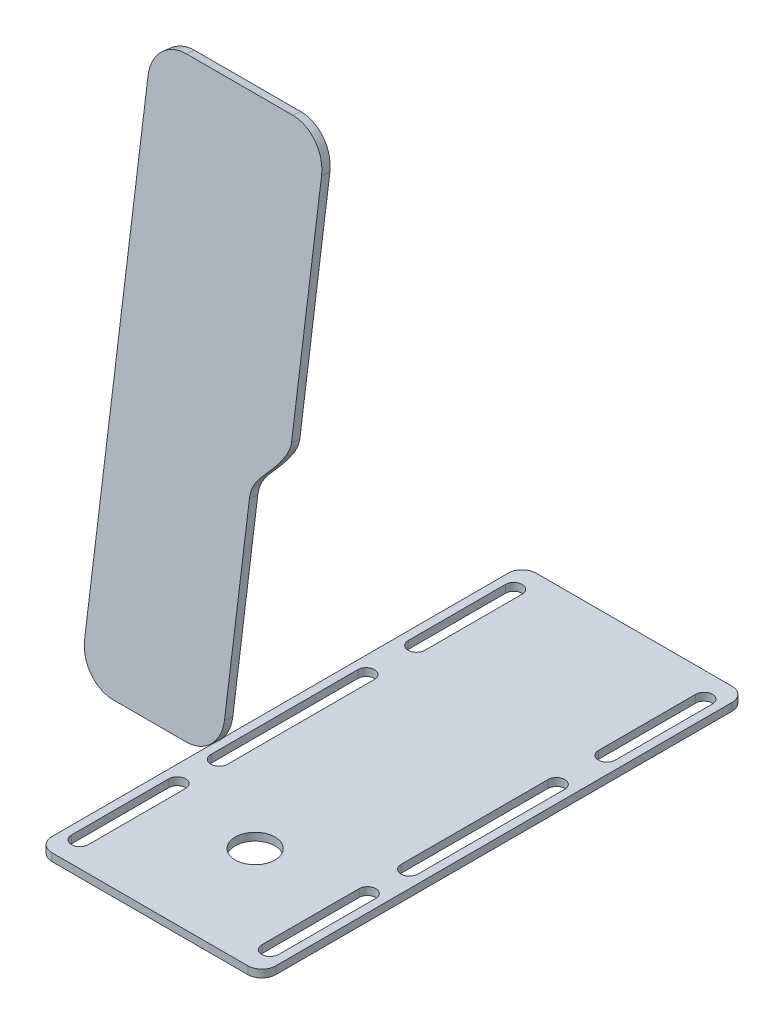
from build123d import *

# Parameters (mm, degrees)
SKETCH1_R           = 7.112045721
BOSS_EXTRUDE1_DEPTH = 2.75
BOSS_EXTRUDE2_DEPTH = 3


with BuildPart() as part:
    # Sketch1 → Boss-Extrude1 (new body)
    with BuildSketch(Plane(origin=(0, 0, 0), x_dir=(1, 0, 0), z_dir=(0, 1, 0))):
        with BuildLine():
            Line((-35, 86.51875), (35, 86.51875))
            ThreePointArc((35, 86.51875), (38.535533906, 85.054283906), (40, 81.51875))
            Line((40, 81.51875), (40, -81.51875))
            ThreePointArc((40, -81.51875), (38.535533906, -85.054283906), (35, -86.51875))
            Line((35, -86.51875), (-35, -86.51875))
            ThreePointArc((-35, -86.51875), (-38.535533906, -85.054283906), (-40, -81.51875))
            Line((-40, -81.51875), (-40, 81.51875))
            ThreePointArc((-40, 81.51875), (-38.535533906, 85.054283906), (-35, 86.51875))
        make_face()
        with Locations((0, -48.920084539)):
            Circle(SKETCH1_R, mode=Mode.SUBTRACT)
        with BuildLine():
            Line((37, 77.51875), (37, 42.76875))
            ThreePointArc((37, 42.76875), (34, 39.76875), (31, 42.76875))
            Line((31, 42.76875), (31, 77.51875))
            ThreePointArc((31, 77.51875), (34, 80.51875), (37, 77.51875))
        make_face(mode=Mode.SUBTRACT)
        with BuildLine():
            Line((-37, 77.51875), (-37, 42.76875))
            ThreePointArc((-37, 42.76875), (-34, 39.76875), (-31, 42.76875))
            Line((-31, 42.76875), (-31, 77.51875))
            ThreePointArc((-31, 77.51875), (-34, 80.51875), (-37, 77.51875))
        make_face(mode=Mode.SUBTRACT)
        with BuildLine():
            Line((37, -77.51875), (37, -42.76875))
            ThreePointArc((37, -42.76875), (34, -39.76875), (31, -42.76875))
            Line((31, -42.76875), (31, -77.51875))
            ThreePointArc((31, -77.51875), (34, -80.51875), (37, -77.51875))
        make_face(mode=Mode.SUBTRACT)
        with BuildLine():
            Line((-37, -77.51875), (-37, -42.76875))
            ThreePointArc((-37, -42.76875), (-34, -39.76875), (-31, -42.76875))
            Line((-31, -42.76875), (-31, -77.51875))
            ThreePointArc((-31, -77.51875), (-34, -80.51875), (-37, -77.51875))
        make_face(mode=Mode.SUBTRACT)
        with BuildLine():
            Line((37, 24.76875), (37, -27.76875))
            ThreePointArc((37, -27.76875), (34, -30.76875), (31, -27.76875))
            Line((31, -27.76875), (31, 24.76875))
            ThreePointArc((31, 24.76875), (34, 27.76875), (37, 24.76875))
        make_face(mode=Mode.SUBTRACT)
        with BuildLine():
            Line((-37, 24.76875), (-37, -27.76875))
            ThreePointArc((-37, -27.76875), (-34, -30.76875), (-31, -27.76875))
            Line((-31, -27.76875), (-31, 24.76875))
            ThreePointArc((-31, 24.76875), (-34, 27.76875), (-37, 24.76875))
        make_face(mode=Mode.SUBTRACT)
    extrude(amount=BOSS_EXTRUDE1_DEPTH)


with BuildPart() as body_2:
    # Sketch3 → Boss-Extrude2 (new body)
    with BuildSketch(Plane(origin=(0, 12.958063193, 93.198377578), x_dir=(0, -0.990472215, 0.137712714), z_dir=(0, 0.137712714, 0.990472215))):
        with BuildLine():
            Line((-125.30290794, 25), (-60.504073198, 25))
            ThreePointArc((-60.504073198, 25), (-52.018791824, 21.485281374), (-48.504073198, 13))
            Line((-48.504073198, 13), (-48.504073198, -13))
            ThreePointArc((-48.504073198, -13), (-52.018791824, -21.485281374), (-60.504073198, -25))
            Line((-60.504073198, -25), (-225.30290794, -25))
            ThreePointArc((-225.30290794, -25), (-233.788189314, -21.485281374), (-237.30290794, -13))
            Line((-237.30290794, -13), (-237.30290794, 25))
            ThreePointArc((-237.30290794, 25), (-233.788189314, 33.485281374), (-225.30290794, 37))
            Line((-225.30290794, 37), (-147.30290794, 37))
            add(Edge.make_bspline(
                [(-147.30290794, 37), (-144.065512893, 37), (-135.5827842, 31), (-129.980550468, 25), (-125.30290794, 25)],
                knots=[0, 0, 0, 0, 0.5, 1, 1, 1, 1], degree=3))
        make_face()
    extrude(amount=-BOSS_EXTRUDE2_DEPTH)


solid = Compound([part.part, body_2.part])
